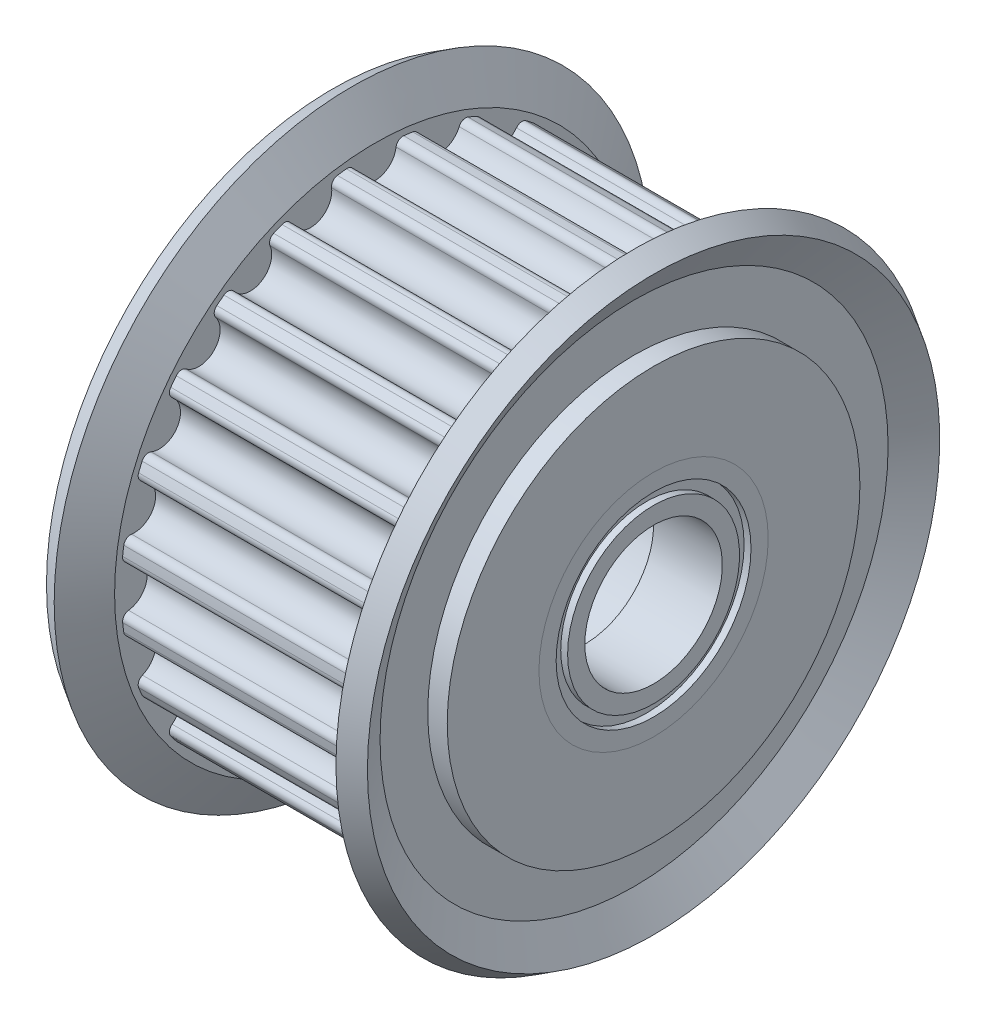
from build123d import *

# Parameters (mm, degrees)
CUT_EXTRUDE1_DEPTH = 8
CIRPATTERN1_COUNT  = 24


with BuildPart() as part:
    # Sketch1 → Revolve1 (revolve)
    with BuildSketch(Plane.XY):
        Polygon((-4, 4.5), (4, 4.5), (4, 5), (7, 5), (7, 9), (5.15, 9), (5.15, 11.08), (-5.15, 11.08), (-5.15, 9), (-7, 9), (-7, 5), (-4, 5), align=None)
    revolve(axis=Axis((-19.462379578, 0, 0), (1, 0, 0)))

    # Sketch4 → Cut-Extrude1 (cut, symmetric)
    with BuildSketch(Plane(origin=(0, 0, 0), x_dir=(0, 0, -1), z_dir=(1, 0, 0))):
        with BuildLine():
            ThreePointArc((-0.918555953, 10.749056513), (0, 9.94), (0.918555953, 10.749056513))
            ThreePointArc((0.918555953, 10.749056513), (1.030902349, 10.947148506), (1.25, 11.009264281))
            ThreePointArc((1.25, 11.009264281), (0, 11.08), (-1.25, 11.009264281))
            ThreePointArc((-1.25, 11.009264281), (-1.030902349, 10.947148506), (-0.918555953, 10.749056513))
        make_face()
    cut_extrude1 = extrude(amount=CUT_EXTRUDE1_DEPTH, both=True, mode=Mode.SUBTRACT)

    # CirPattern1: Cut-Extrude1 ×24 about axis
    cirpattern1_axis = Axis((0, 0, 0), (1, 0, 0))
    for i in range(1, CIRPATTERN1_COUNT):
        add(cut_extrude1.rotate(cirpattern1_axis, i * 360 / CIRPATTERN1_COUNT), mode=Mode.SUBTRACT)


with BuildPart() as body_2:
    # Sketch2 → Revolve2 (revolve)
    with BuildSketch(Plane.XY):
        Polygon((5.15, 9), (6.15, 9), (6.15, 11.08), (7, 12.481401148), (6.144982322, 13), (5.15, 11.35956545), align=None)
        Polygon((-5.15, 11.35956545), (-5.15, 9), (-6.15, 9), (-6.15, 11.08), (-7, 12.481401148), (-6.144982322, 13), align=None)
    revolve(axis=Axis((-11.316441619, 0, 0), (1, 0, 0)))


with BuildPart() as body_3:
    # Sketch5 → Revolve3 (revolve)
    with BuildSketch(Plane.XY):
        Polygon((4, 3.75), (4, 3), (7, 3), (7, 3.75), (6.7, 3.75), (6.7, 4.25), (7, 4.25), (7, 5), (4, 5), (4, 4.25), (4.3, 4.25), (4.3, 3.75), align=None)
        Polygon((-7, 4.25), (-6.7, 4.25), (-6.7, 3.75), (-7, 3.75), (-7, 3), (-4, 3), (-4, 3.75), (-4.3, 3.75), (-4.3, 4.25), (-4, 4.25), (-4, 5), (-7, 5), align=None)
    revolve(axis=Axis((0, 0, 0), (1, 0, 0)))


solid = Compound([part.part, body_2.part, body_3.part])
